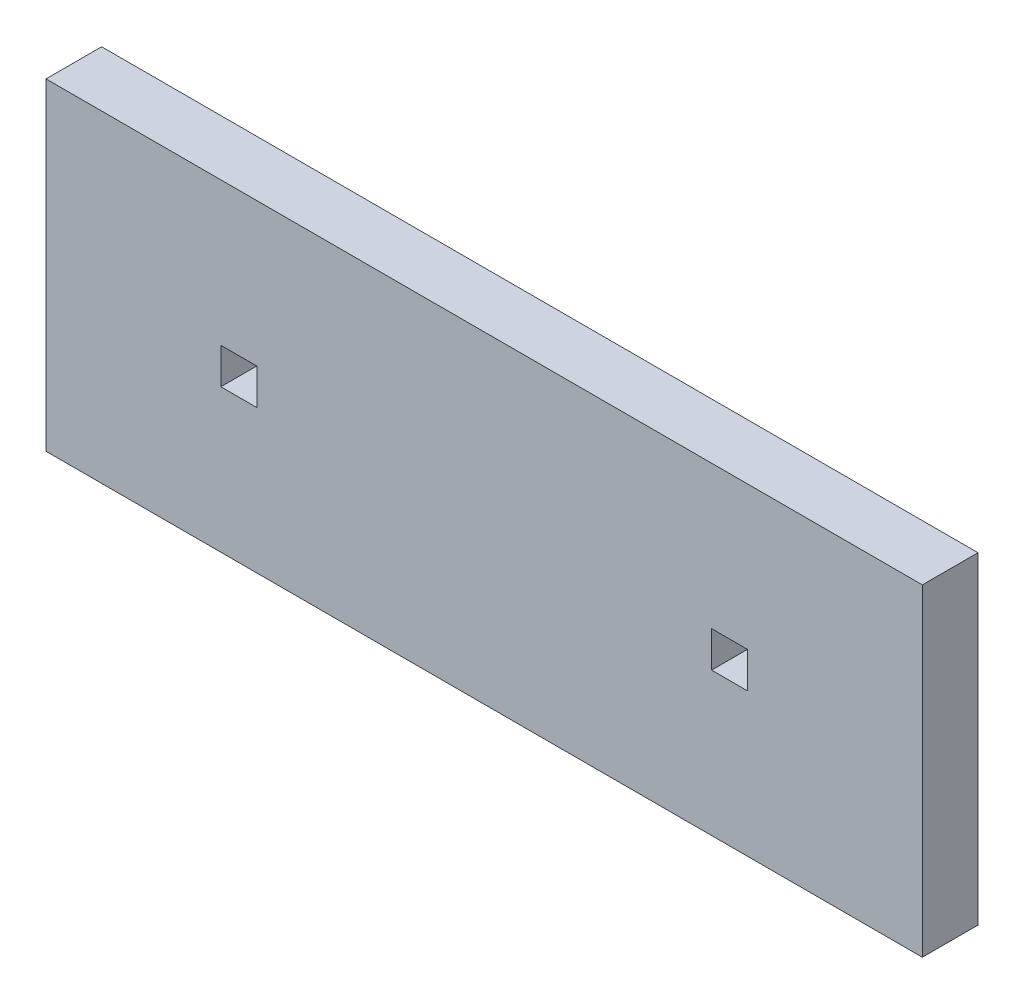
from build123d import *

# Parameters (mm, degrees)
SKETCH2_W           = 2.05
SKETCH2_H           = 2.05
BOSS_EXTRUDE1_DEPTH = 3.175


with BuildPart() as part:
    # Sketch2 → Boss-Extrude1 (new body)
    with BuildSketch(Plane.XY):
        Polygon((-25, -10.7874943), (25, -10.7874943), (25, -1), (25, 1), (25, 7.6124943), (22.5, 7.6124943), (20.5, 7.6124943), (18, 7.6124943), (-18, 7.6124943), (-20.5, 7.6124943), (-22.5, 7.6124943), (-25, 7.6124943), (-25, 1), (-25, -1), align=None)
        with Locations((-14, -1.5874943)):
            Rectangle(SKETCH2_W, SKETCH2_H, mode=Mode.SUBTRACT)
        with Locations((14, -1.5874943)):
            Rectangle(SKETCH2_W, SKETCH2_H, mode=Mode.SUBTRACT)
    extrude(amount=BOSS_EXTRUDE1_DEPTH)


solid = part.part
